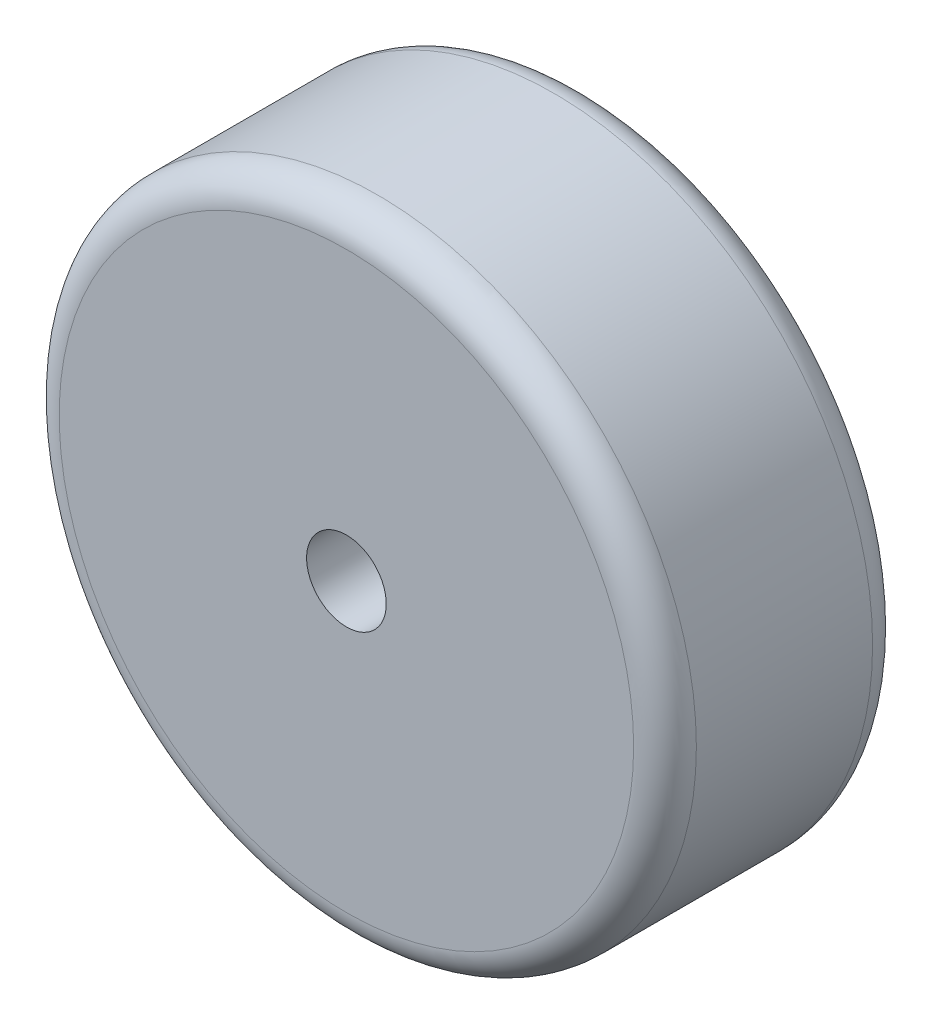
from build123d import *

# Parameters (mm, degrees)
SKETCH1_R           = 101.6
SKETCH1_R_2         = 12.7
BOSS_EXTRUDE1_DEPTH = 38.1
FILLET1_R           = 10


with BuildPart() as part:
    # Sketch1 → Boss-Extrude1 (new body, symmetric)
    with BuildSketch(Plane.XY):
        Circle(SKETCH1_R)
        Circle(SKETCH1_R_2, mode=Mode.SUBTRACT)
    extrude(amount=BOSS_EXTRUDE1_DEPTH, both=True)

    # Fillet1
    fillet1_edges = [part.edges().sort_by_distance(p)[0] for p in [
        (-101.6, 0, -38.1),
        (-101.6, 0, 38.1),
    ]]
    fillet(fillet1_edges, radius=FILLET1_R)


solid = part.part
